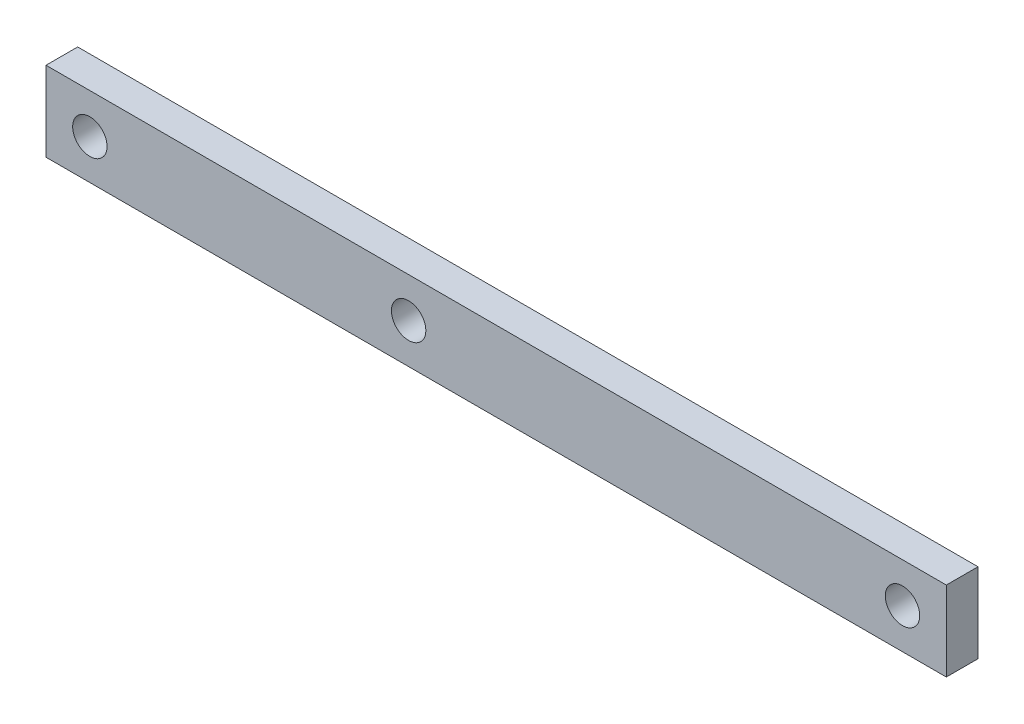
from build123d import *

# Parameters (mm, degrees)
SKETCH1_W           = 90.38
SKETCH1_H           = 8
BOSS_EXTRUDE1_DEPTH = 3.18
SKETCH2_R           = 1.7272
CUT_EXTRUDE1_DEPTH  = 4.18
LPATTERN1_COUNT     = 2
LPATTERN1_PITCH     = 32
LPATTERN2_COUNT     = 2
LPATTERN2_PITCH     = 81.58


with BuildPart() as part:
    # Sketch1 → Boss-Extrude1 (new body)
    with BuildSketch(Plane.XY):
        with Locations((45.19, 4)):
            Rectangle(SKETCH1_W, SKETCH1_H)
    extrude(amount=BOSS_EXTRUDE1_DEPTH)

    # Sketch2 → Cut-Extrude1 (cut, through all)
    with BuildSketch(Plane.XY.offset(3.18)):
        with Locations((4.402357816, 4)):
            Circle(SKETCH2_R)
    cut_extrude1 = extrude(amount=-CUT_EXTRUDE1_DEPTH, mode=Mode.SUBTRACT)

    # LPattern1: Cut-Extrude1 ×2
    with Locations(*[(i * LPATTERN1_PITCH, 0, 0) for i in range(1, LPATTERN1_COUNT)]):
        add(cut_extrude1, mode=Mode.SUBTRACT)

    # LPattern2: Cut-Extrude1 ×2
    with Locations(*[(i * LPATTERN2_PITCH, 0, 0) for i in range(1, LPATTERN2_COUNT)]):
        add(cut_extrude1, mode=Mode.SUBTRACT)


solid = part.part
